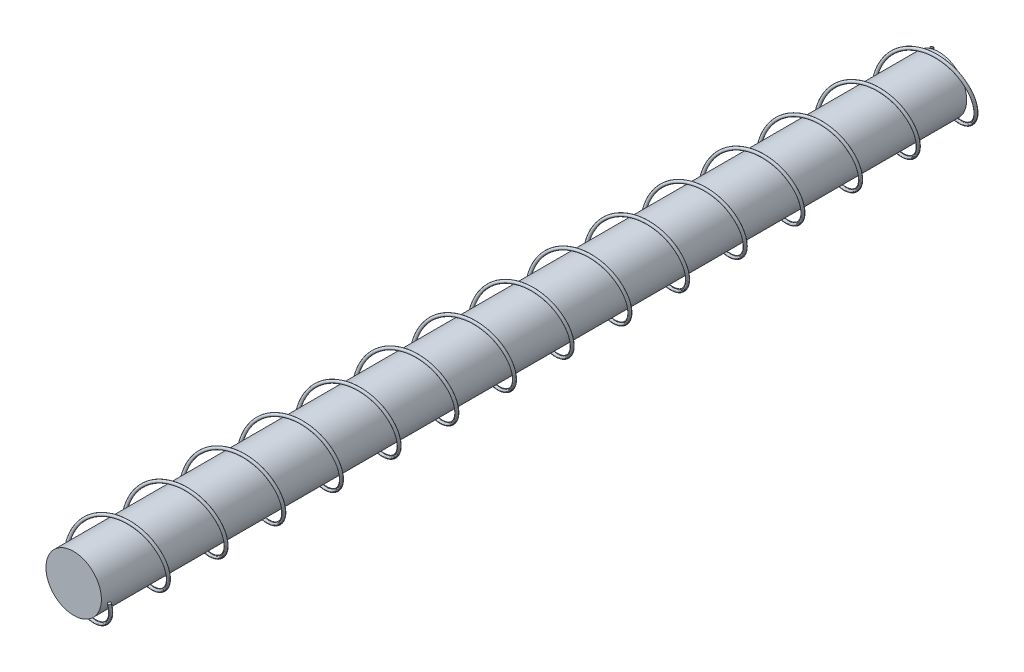
from build123d import *

# Parameters (mm, degrees)
IZIM1_R                     = 0.961533242
Y_KSEKLIK_EKSTR_ZYON1_DEPTH = 30
S_P_R1_PITCH                = 2
S_P_R1_HEIGHT               = 31
S_P_R1_RADIUS               = 1.237735531
S_P_R1_START_ANGLE          = 179
IZIM4_R                     = 0.050090045


with BuildPart() as part:
    # Çizim1 → Yükseklik-Ekstrüzyon1 (new body)
    with BuildSketch(Plane.XY):
        Circle(IZIM1_R)
    extrude(amount=Y_KSEKLIK_EKSTR_ZYON1_DEPTH)


with BuildPart() as body_2:
    # Süpür1: sweep along a helix
    with BuildLine() as s_p_r1_path:
        add(Helix(S_P_R1_PITCH, S_P_R1_HEIGHT, S_P_R1_RADIUS, center=(0, 0, 30), direction=(0, 0, -1), mode=Mode.PRIVATE).rotate(Axis((0, 0, 30), (0, 0, -1)), S_P_R1_START_ANGLE))
    # Çizim4 → Süpür1 (sweep)
    with BuildSketch(Plane(origin=(-1.237547018, -0.021601464, -1), x_dir=(0.999857144, 0.016369605, -0.004210432), z_dir=(-0.016902417, 0.968338815, -0.249066754))):
        Circle(IZIM4_R)
    sweep(path=s_p_r1_path.line, is_frenet=True)


solid = Compound([part.part, body_2.part])
